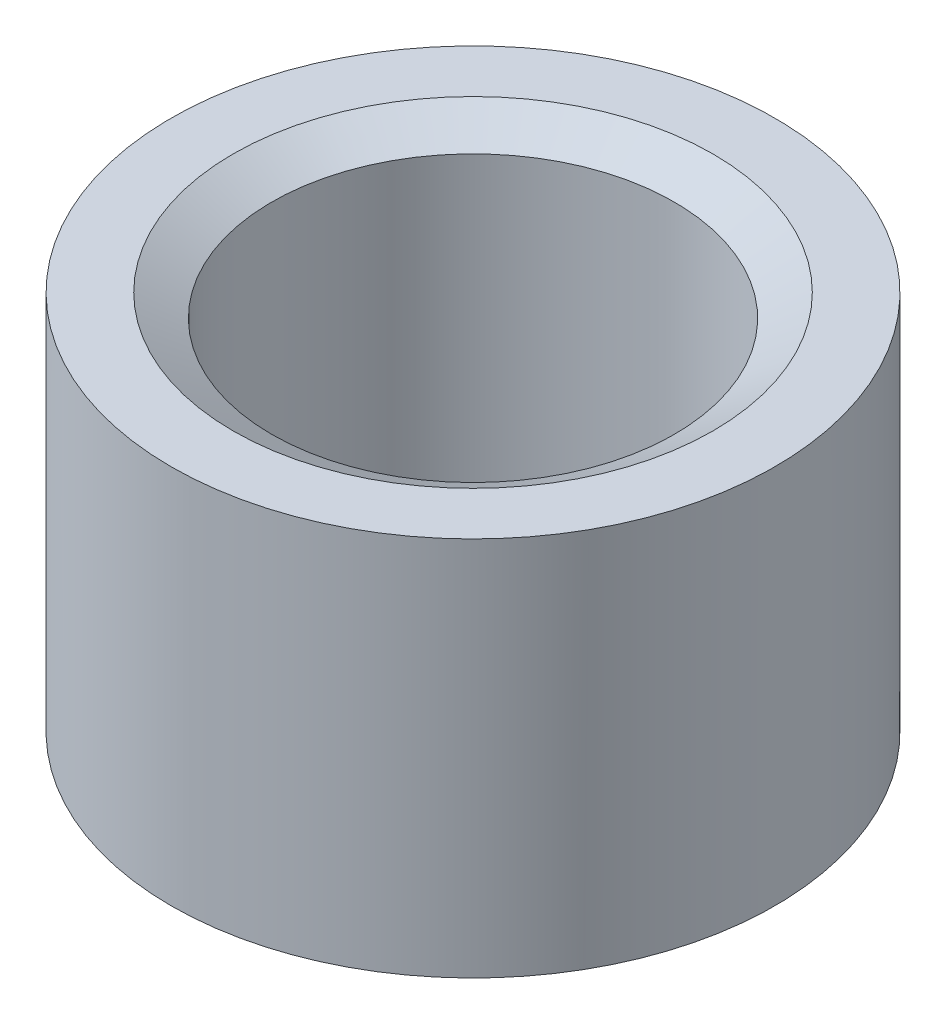
from build123d import *

# Parameters (mm, degrees)
SKETCH1_W             = 0.79375
SKETCH1_H             = 3.175
CHAMFER1_SIZE         = 0.3048
CHAMFER1_SIZE2        = 0.175976362
CHAMFER1_PART_2_SIZE  = 0.3048
CHAMFER1_PART_2_SIZE2 = 0.175976362


with BuildPart() as part:
    # Sketch1 → Revolve1 (revolve)
    with BuildSketch(Plane(origin=(0, 0, 0), x_dir=(1, 0, 0), z_dir=(0, 0, -1))):
        with Locations((1.984375, 1.5875)):
            Rectangle(SKETCH1_W, SKETCH1_H)
    revolve(axis=Axis((0, 0, 0), (0, -1, 0)))

    # Chamfer1
    chamfer1_edges = [part.edges().sort_by_distance(p)[0] for p in [
        (-1.5875, 0, 0),
    ]]
    chamfer1_side = [part.faces().sort_by_distance(p)[0] for p in [
        (-2.313898079, 0, 0),
    ]]
    chamfer(chamfer1_edges, length=CHAMFER1_SIZE, length2=CHAMFER1_SIZE2, reference=chamfer1_side[0])

    # Chamfer1 part 2
    chamfer1_part_2_edges = [part.edges().sort_by_distance(p)[0] for p in [
        (-2.38125, -3.175, 0),
    ]]
    chamfer1_part_2_side = [part.faces().sort_by_distance(p)[0] for p in [
        (-1.654851921, -3.175, 0),
    ]]
    chamfer(chamfer1_part_2_edges, length=CHAMFER1_PART_2_SIZE, length2=CHAMFER1_PART_2_SIZE2, reference=chamfer1_part_2_side[0])


solid = part.part
